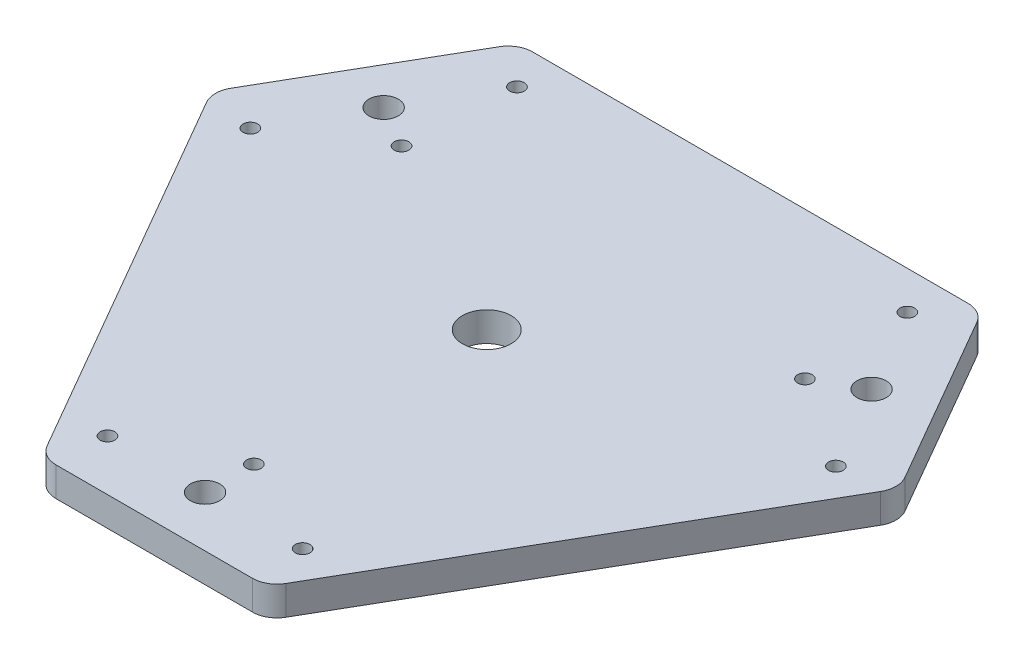
from build123d import *

# Parameters (mm, degrees)
BOSS_EXTRUDE1_DEPTH = 6
SKETCH2_R           = 3
SKETCH2_R_2         = 1.5
CUT_EXTRUDE1_DEPTH  = 7
FILLET1_R           = 5
SKETCH4_R           = 5
CUT_EXTRUDE3_DEPTH  = 7


with BuildPart() as part:
    # Sketch1 → Boss-Extrude1 (new body)
    with BuildSketch(Plane(origin=(0, 0, 0), x_dir=(1, 0, 0), z_dir=(0, 1, 0))):
        Polygon((-47.5, 54), (47.5, 54), (70.515371804, 14.13620668), (23.015371804, -68.13620668), (-23.015371804, -68.13620668), (-70.515371804, 14.13620668), align=None)
    extrude(amount=BOSS_EXTRUDE1_DEPTH)

    # Sketch2 → Cut-Extrude1 (cut, through all)
    with BuildSketch(Plane(origin=(0, 6, 0), x_dir=(1, 0, 0), z_dir=(0, 1, 0))):
        with Locations((50, 28.867513459)):
            Circle(SKETCH2_R)
        with Locations((-50, 28.867513459)):
            Circle(SKETCH2_R)
        with Locations((0, -57.735026919)):
            Circle(SKETCH2_R)
        with Locations((-20, -57.735026919)):
            Circle(SKETCH2_R_2)
        with Locations((20, -57.735026919)):
            Circle(SKETCH2_R_2)
        with Locations((0, -47.735026919)):
            Circle(SKETCH2_R_2)
        with Locations((-60, 11.547005384)):
            Circle(SKETCH2_R_2)
        with Locations((-41.339745962, 23.867513459)):
            Circle(SKETCH2_R_2)
        with Locations((-40, 46.188021535)):
            Circle(SKETCH2_R_2)
        with Locations((40, 46.188021535)):
            Circle(SKETCH2_R_2)
        with Locations((41.339745962, 23.867513459)):
            Circle(SKETCH2_R_2)
        with Locations((60, 11.547005384)):
            Circle(SKETCH2_R_2)
    extrude(amount=-CUT_EXTRUDE1_DEPTH, mode=Mode.SUBTRACT)

    # Fillet1
    fillet1_edges = [part.edges().sort_by_distance(p)[0] for p in [
        (-47.5, 3, -54),
        (47.5, 3, -54),
        (70.515371804, 3, -14.13620668),
        (23.015371804, 3, 68.13620668),
        (-23.015371804, 3, 68.13620668),
        (-70.515371804, 3, -14.13620668),
    ]]
    fillet(fillet1_edges, radius=FILLET1_R)

    # Sketch4 → Cut-Extrude3 (cut, through all)
    with BuildSketch(Plane(origin=(0, 6, 0), x_dir=(1, 0, 0), z_dir=(0, 1, 0))):
        Circle(SKETCH4_R)
    extrude(amount=-CUT_EXTRUDE3_DEPTH, mode=Mode.SUBTRACT)


solid = part.part
